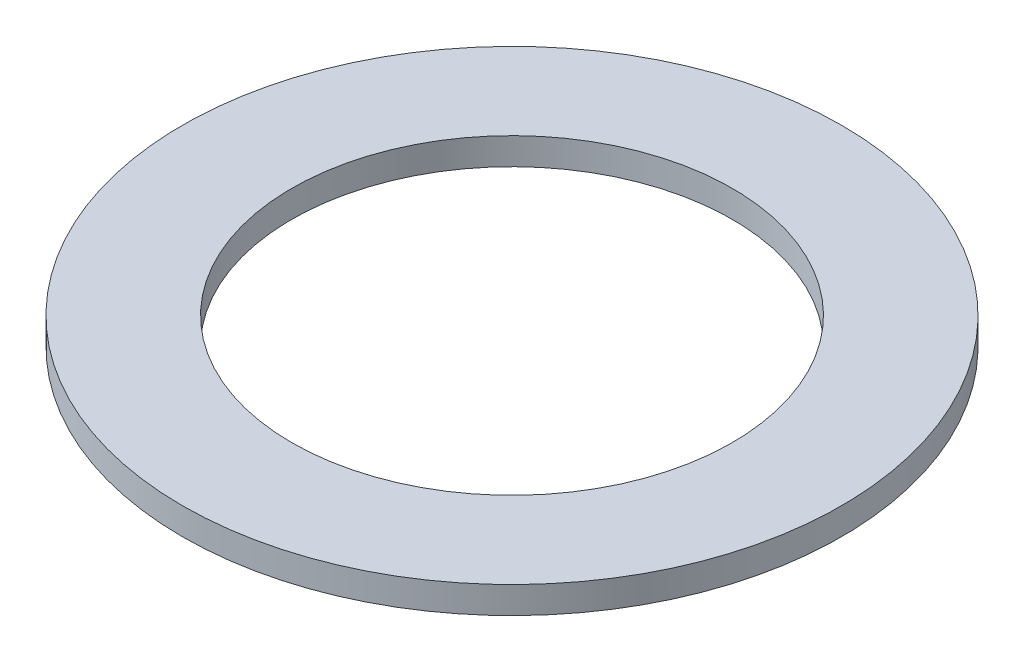
from build123d import *

# Parameters (mm, degrees)
SKETCH1_R           = 12.25
SKETCH1_R_2         = 8.1875
BOSS_EXTRUDE1_DEPTH = 1


with BuildPart() as part:
    # Sketch1 → Boss-Extrude1 (new body)
    with BuildSketch(Plane(origin=(0, 0, 0), x_dir=(1, 0, 0), z_dir=(0, 1, 0))):
        Circle(SKETCH1_R)
        Circle(SKETCH1_R_2, mode=Mode.SUBTRACT)
    extrude(amount=BOSS_EXTRUDE1_DEPTH)


solid = part.part
